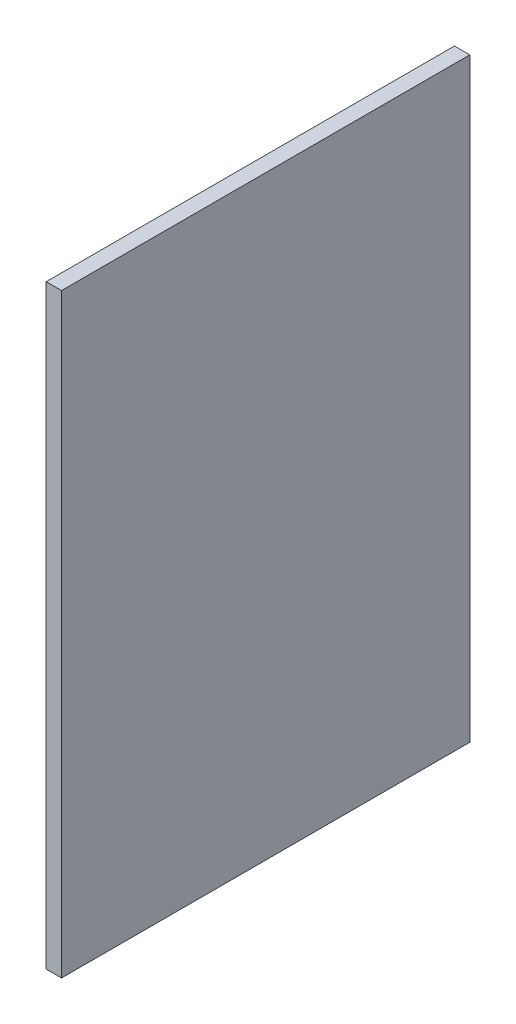
from build123d import *

# Parameters (mm, degrees)
SKETCH1_W           = 480
SKETCH1_H           = 700
BOSS_EXTRUDE1_DEPTH = 18


with BuildPart() as part:
    # Sketch1 → Boss-Extrude1 (new body)
    with BuildSketch(Plane(origin=(0, 0, 0), x_dir=(0, 0, -1), z_dir=(1, 0, 0))):
        with Locations((205.496486702, -305.890394931)):
            Rectangle(SKETCH1_W, SKETCH1_H)
    extrude(amount=BOSS_EXTRUDE1_DEPTH)


solid = part.part
